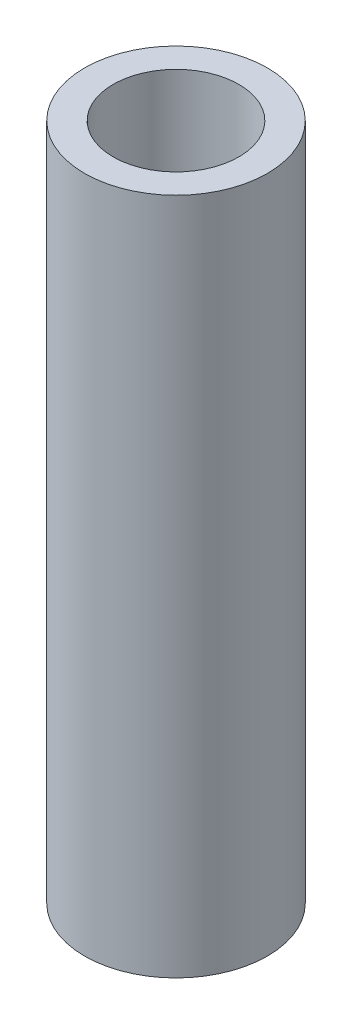
from build123d import *

# Parameters (mm, degrees)
SKETCH1_R               = 7.4168
BOSS_EXTRUDE1_DEPTH     = 55
M12X1_75_TAPPED_HOLE1_D = 10.2


with BuildPart() as part:
    # Sketch1 → Boss-Extrude1 (new body)
    with BuildSketch(Plane(origin=(0, 0, 0), x_dir=(1, 0, 0), z_dir=(0, 1, 0))):
        Circle(SKETCH1_R)
    extrude(amount=BOSS_EXTRUDE1_DEPTH)

    # M12x1.75 Tapped Hole1 (through all)
    with Locations(Plane(origin=(0, 55, 0), x_dir=(1, 0, 0), z_dir=(0, 1, 0))):
        with Locations((0, 0)):
            Hole(M12X1_75_TAPPED_HOLE1_D / 2)


solid = part.part
